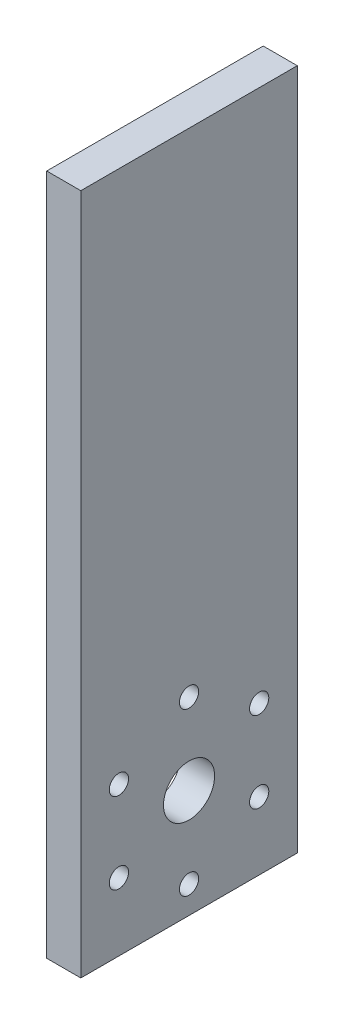
from build123d import *

# Parameters (mm, degrees)
SKETCH2_W                 = 4
SKETCH2_H                 = 25.4
BOSS_EXTRUDE1_DEPTH       = 80
F_4_40_TAPPED_HOLE1_D     = 2.2606
F_4_40_TAPPED_HOLE1_DEPTH = 7.6
F_4_40_TAPPED_HOLE1_TIP   = 0.679152758
SKETCH6_R                 = 3
CUT_EXTRUDE1_DEPTH        = 80


with BuildPart() as part:
    # Sketch2 → Boss-Extrude1 (new body)
    with BuildSketch(Plane(origin=(0, 0, 0), x_dir=(1, 0, 0), z_dir=(0, 1, 0))):
        with Locations((2, -12.7)):
            Rectangle(SKETCH2_W, SKETCH2_H)
    extrude(amount=BOSS_EXTRUDE1_DEPTH)

    # #4-40 Tapped Hole1
    with Locations(Plane(origin=(4, 0, 0), x_dir=(0, 0, -1), z_dir=(1, 0, 0))):
        with Locations((-12.7, 22.2), (-4.472758664, 17.45), (-4.472758664, 7.95), (-12.7, 3.2), (-20.927241336, 7.95), (-20.927241336, 17.45)):
            Hole(F_4_40_TAPPED_HOLE1_D / 2, depth=F_4_40_TAPPED_HOLE1_DEPTH)
            with Locations((0, 0, -(F_4_40_TAPPED_HOLE1_DEPTH + F_4_40_TAPPED_HOLE1_TIP / 2))):  # 118° drill point
                Cone(0, F_4_40_TAPPED_HOLE1_D / 2, F_4_40_TAPPED_HOLE1_TIP, mode=Mode.SUBTRACT)

    # Sketch6 → Cut-Extrude1 (cut)
    with BuildSketch(Plane(origin=(4, 0, 0), x_dir=(0, 0, -1), z_dir=(1, 0, 0))):
        with Locations((-12.7, 12.7)):
            Circle(SKETCH6_R)
    extrude(amount=-CUT_EXTRUDE1_DEPTH, mode=Mode.SUBTRACT)


solid = part.part
